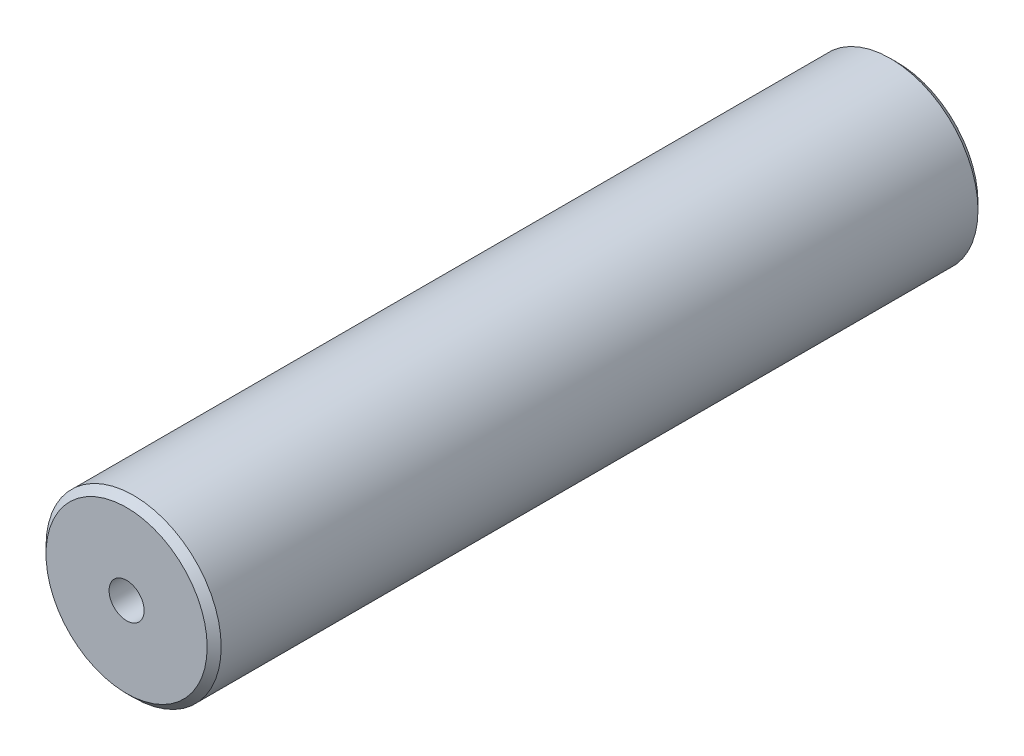
from build123d import *

# Parameters (mm, degrees)
SKETCH1_R           = 12.5
BOSS_EXTRUDE1_DEPTH = 55
CHAMFER1_SIZE       = 1


with BuildPart() as part:
    # Sketch1 → Boss-Extrude1 (new body, symmetric)
    with BuildSketch(Plane.XY):
        Circle(SKETCH1_R)
    extrude(amount=BOSS_EXTRUDE1_DEPTH, both=True)

    # Chamfer1
    chamfer1_edges = [part.edges().sort_by_distance(p)[0] for p in [
        (-12.5, 0, -55),
        (-12.5, 0, 55),
    ]]
    chamfer(chamfer1_edges, length=CHAMFER1_SIZE)

    # Sketch4 → M6 Tapped Hole1 (revolve, cut)
    with BuildSketch(Plane(origin=(0, 0, 55), x_dir=(0, -1, 0), z_dir=(1, 0, 0))):
        Polygon((0, 0), (0, 16.502151548), (2.5, 15), (2.5, 0), align=None)
    m6_tapped_hole1 = revolve(axis=Axis((0, 0, 61.35), (0, 0, -1)), mode=Mode.SUBTRACT)

    # Mirror1: M6 Tapped Hole1 across plane
    add(m6_tapped_hole1.mirror(Plane.XY), mode=Mode.SUBTRACT)


solid = part.part
